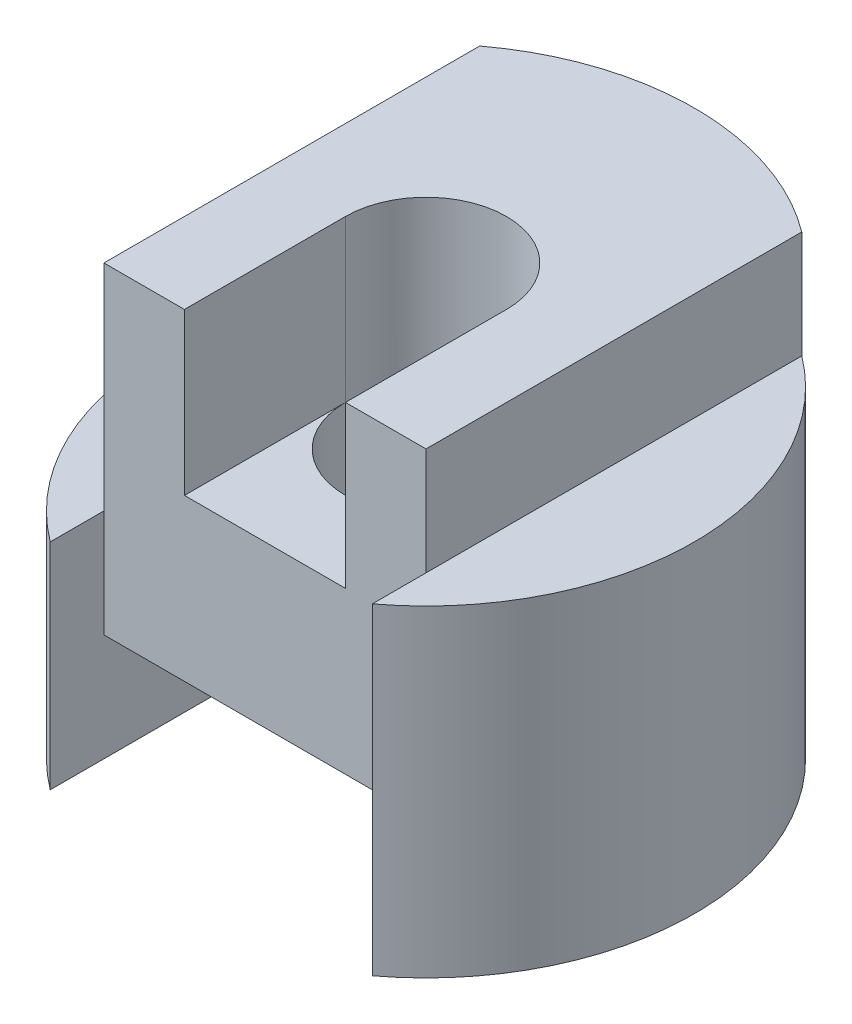
from build123d import *

# Parameters (mm, degrees)
SKETCH1_R           = 1.5
BOSS_EXTRUDE1_DEPTH = 8
SKETCH2_W           = 2
SKETCH2_H           = 2
SKETCH2_H_2         = 4
SKETCH2_W_2         = 6
CUT_EXTRUDE1_DEPTH  = 9
SKETCH3_W           = 3
SKETCH3_H           = 3
CUT_EXTRUDE2_DEPTH  = 18


with BuildPart() as part:
    # Sketch1 → Boss-Extrude1 (new body)
    with BuildSketch(Plane(origin=(0, 0, 0), x_dir=(1, 0, 0), z_dir=(0, 1, 0))):
        with BuildLine():
            Line((-3, -4), (-3, -3))
            Line((-3, -3), (3, -3))
            Line((3, -3), (3, -4))
            ThreePointArc((3, -4), (0, 5), (-3, -4))
        make_face()
        Circle(SKETCH1_R, mode=Mode.SUBTRACT)
    extrude(amount=BOSS_EXTRUDE1_DEPTH)

    # Sketch2 → Cut-Extrude1 (cut, symmetric)
    with BuildSketch(Plane.XY):
        with Locations((4, 7)):
            Rectangle(SKETCH2_W, SKETCH2_H)
        with Locations((-4, 6)):
            Rectangle(SKETCH2_W, SKETCH2_H_2)
        with Locations((0, 1)):
            Rectangle(SKETCH2_W_2, SKETCH2_H)
    extrude(amount=CUT_EXTRUDE1_DEPTH, both=True, mode=Mode.SUBTRACT)

    # Sketch3 → Cut-Extrude2 (cut)
    with BuildSketch(Plane.XY):
        with Locations((0, 6.5)):
            Rectangle(SKETCH3_W, SKETCH3_H)
    extrude(amount=CUT_EXTRUDE2_DEPTH, mode=Mode.SUBTRACT)


solid = part.part
